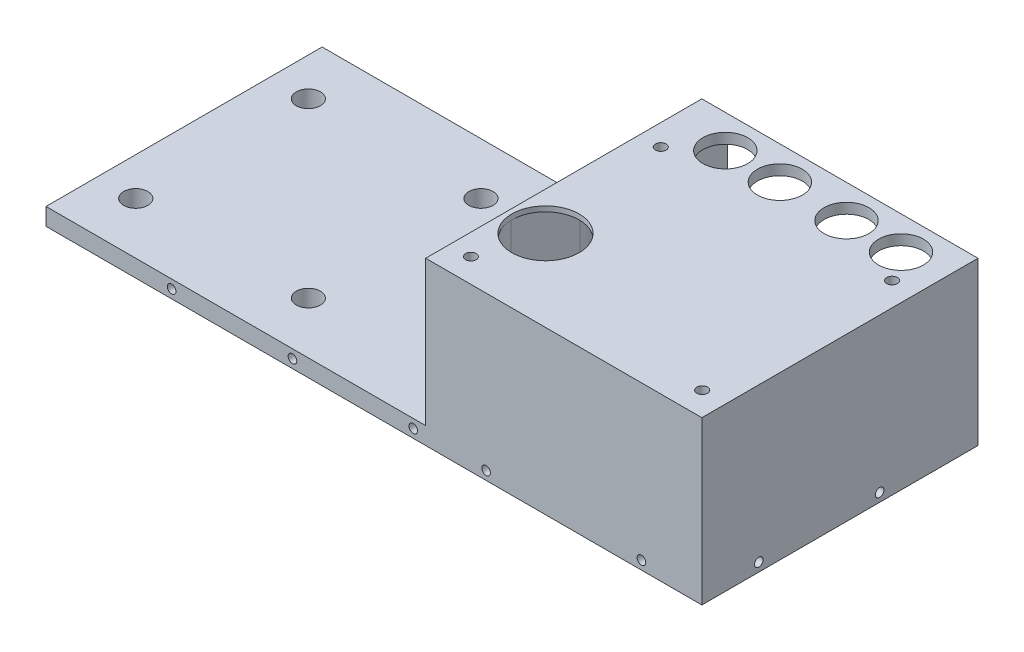
from build123d import *

# Parameters (mm, degrees)
SKETCH1_W                  = 190
SKETCH1_H                  = 80
BOSS_EXTRUDE1_DEPTH        = 5
SKETCH3_W                  = 80
SKETCH3_H                  = 80
BOSS_EXTRUDE2_DEPTH        = 42
SKETCH5_R                  = 6.5
CUT_EXTRUDE2_DEPTH         = 48
CUT_EXTRUDE3_DEPTH         = 44
SKETCH7_R                  = 3.5
CUT_EXTRUDE4_DEPTH         = 48
SKETCH8_R                  = 9.75
CUT_EXTRUDE5_DEPTH         = 48
SKETCH4_R                  = 1.55
CUT_EXTRUDE1_DEPTH         = 48
SKETCH9_R                  = 3.5
CUT_EXTRUDE6_DEPTH         = 44
SKETCH10_R                 = 10
CUT_EXTRUDE7_DEPTH         = 45.5
M3_TAPPED_HOLE1_AT_2_COUNT = 2
M3_TAPPED_HOLE1_AT_2_PITCH = 35
M3_TAPPED_HOLE1_AT_3_COUNT = 2
M3_TAPPED_HOLE1_AT_3_PITCH = 70
M3_TAPPED_HOLE2_D          = 2.5
M3_TAPPED_HOLE2_DEPTH      = 7.5
M3_TAPPED_HOLE2_TIP        = 0.751075774
M3_TAPPED_HOLE3_D          = 2.5
M3_TAPPED_HOLE3_DEPTH      = 7.5
M3_TAPPED_HOLE3_TIP        = 0.751075774
CUT_EXTRUDE8_DEPTH         = 45.5
FILLET1_R                  = 5
SKETCH_1_W                 = 68.9
SKETCH_1_H                 = 9.6
CUT_EXTRUDE_1_DEPTH        = 44


with BuildPart() as part:
    # Sketch1 → Boss-Extrude1 (new body)
    with BuildSketch(Plane(origin=(0, 0, 0), x_dir=(1, 0, 0), z_dir=(0, 1, 0))):
        Rectangle(SKETCH1_W, SKETCH1_H)
    extrude(amount=BOSS_EXTRUDE1_DEPTH)

    # Sketch3 → Boss-Extrude2 (add)
    with BuildSketch(Plane(origin=(0, 5, 0), x_dir=(1, 0, 0), z_dir=(0, 1, 0))):
        with Locations((55, 0)):
            Rectangle(SKETCH3_W, SKETCH3_H)
    extrude(amount=BOSS_EXTRUDE2_DEPTH)

    # Sketch5 → Cut-Extrude2 (cut, through all)
    with BuildSketch(Plane.XZ):
        with Locations((31.4, -30.4)):
            Circle(SKETCH5_R)
        with Locations((47.2, -30.4)):
            Circle(SKETCH5_R)
        with Locations((66.5, -30.4)):
            Circle(SKETCH5_R)
        with Locations((82.3, -30.4)):
            Circle(SKETCH5_R)
    extrude(amount=-CUT_EXTRUDE2_DEPTH, mode=Mode.SUBTRACT)

    # Sketch6 → Cut-Extrude3 (cut)
    with BuildSketch(Plane.XZ):
        with BuildLine():
            Line((31.4, -21.4), (82.3, -21.4))
            ThreePointArc((82.3, -21.4), (91.3, -30.4), (82.3, -39.4))
            Line((82.3, -39.4), (31.4, -39.4))
            ThreePointArc((31.4, -39.4), (22.4, -30.4), (31.4, -21.4))
        make_face()
    extrude(amount=-CUT_EXTRUDE3_DEPTH, mode=Mode.SUBTRACT)

    # Sketch7 → Cut-Extrude4 (cut, through all)
    with BuildSketch(Plane.XZ):
        with Locations((-84, 25)):
            Circle(SKETCH7_R)
        with Locations((-34, 25)):
            Circle(SKETCH7_R)
        with Locations((-84, -25)):
            Circle(SKETCH7_R)
        with Locations((-34, -25)):
            Circle(SKETCH7_R)
    extrude(amount=-CUT_EXTRUDE4_DEPTH, mode=Mode.SUBTRACT)

    # Sketch8 → Cut-Extrude5 (cut, through all)
    with BuildSketch(Plane.XZ):
        with Locations((26.1, 16.4)):
            Circle(SKETCH8_R)
    extrude(amount=-CUT_EXTRUDE5_DEPTH, mode=Mode.SUBTRACT)

    # Sketch4 → Cut-Extrude1 (cut, through all)
    with BuildSketch(Plane(origin=(0, 47, 0), x_dir=(1, 0, 0), z_dir=(0, 1, 0))):
        with Locations((21.15, 21.95)):
            Circle(SKETCH4_R)
        with Locations((88.15, 21.95)):
            Circle(SKETCH4_R)
        with Locations((21.15, -33.05)):
            Circle(SKETCH4_R)
        with Locations((88.15, -33.05)):
            Circle(SKETCH4_R)
    extrude(amount=-CUT_EXTRUDE1_DEPTH, mode=Mode.SUBTRACT)

    # Sketch9 → Cut-Extrude6 (cut)
    with BuildSketch(Plane.XZ):
        with Locations((21.15, -21.95)):
            Circle(SKETCH9_R)
        with Locations((88.15, -21.95)):
            Circle(SKETCH9_R)
        with Locations((21.15, 33.05)):
            Circle(SKETCH9_R)
        with Locations((88.15, 33.05)):
            Circle(SKETCH9_R)
    extrude(amount=-CUT_EXTRUDE6_DEPTH, mode=Mode.SUBTRACT)

    # Sketch10 → Cut-Extrude7 (cut)
    with BuildSketch(Plane.XZ):
        with Locations((26.1, 16.4)):
            Circle(SKETCH10_R)
    extrude(amount=-CUT_EXTRUDE7_DEPTH, mode=Mode.SUBTRACT)

    # Sketch15 → M3 Tapped Hole1 (revolve, cut)
    with BuildSketch(Plane(origin=(11.4, 2.5, -40), x_dir=(0, 1, 0), z_dir=(1, 0, 0))):
        Polygon((0, 0), (0, 9.251075774), (1.25, 8.5), (1.25, 0), align=None)
    m3_tapped_hole1 = revolve(axis=Axis((11.4, 2.5, -46.35), (0, 0, 1)), mode=Mode.SUBTRACT)

    # M3 Tapped Hole1 at 2: M3 Tapped Hole1 ×2
    with Locations(*[(-i * M3_TAPPED_HOLE1_AT_2_PITCH, 0, 0) for i in range(1, M3_TAPPED_HOLE1_AT_2_COUNT)]):
        add(m3_tapped_hole1, mode=Mode.SUBTRACT)

    # M3 Tapped Hole1 at 3: M3 Tapped Hole1 ×2
    with Locations(*[(-i * M3_TAPPED_HOLE1_AT_3_PITCH, 0, 0) for i in range(1, M3_TAPPED_HOLE1_AT_3_COUNT)]):
        add(m3_tapped_hole1, mode=Mode.SUBTRACT)

    # Mirror1: M3 Tapped Hole1 across plane
    add(m3_tapped_hole1.mirror(Plane.XY), mode=Mode.SUBTRACT)

    # Mirror1 copy 1 sketch → Mirror1 copy 1 (revolve, cut)
    with BuildSketch(Plane(origin=(-23.6, 2.5, 40), x_dir=(0, 1, 0), z_dir=(1, 0, 0))):
        Polygon((0, 0), (0, -9.251075774), (1.25, -8.5), (1.25, 0), align=None)
    revolve(axis=Axis((-23.6, 2.5, 46.35), (0, 0, 1)), mode=Mode.SUBTRACT)

    # Mirror1 copy 2 sketch → Mirror1 copy 2 (revolve, cut)
    with BuildSketch(Plane(origin=(-58.6, 2.5, 40), x_dir=(0, 1, 0), z_dir=(1, 0, 0))):
        Polygon((0, 0), (0, -9.251075774), (1.25, -8.5), (1.25, 0), align=None)
    revolve(axis=Axis((-58.6, 2.5, 46.35), (0, 0, 1)), mode=Mode.SUBTRACT)

    # M3 Tapped Hole2
    with Locations(Plane(origin=(32.5, 2.5, 40), x_dir=(1, 0, 0), z_dir=(0, 0, 1))):
        with Locations((0, 0), (45, 0)):
            Hole(M3_TAPPED_HOLE2_D / 2, depth=M3_TAPPED_HOLE2_DEPTH)
            with Locations((0, 0, -(M3_TAPPED_HOLE2_DEPTH + M3_TAPPED_HOLE2_TIP / 2))):  # 118° drill point
                Cone(0, M3_TAPPED_HOLE2_D / 2, M3_TAPPED_HOLE2_TIP, mode=Mode.SUBTRACT)

    # M3 Tapped Hole3
    with Locations(Plane(origin=(95, 2.5, 23.5), x_dir=(0, 0, 1), z_dir=(1, 0, 0))):
        with Locations((0, 0), (-35, 0)):
            Hole(M3_TAPPED_HOLE3_D / 2, depth=M3_TAPPED_HOLE3_DEPTH)
            with Locations((0, 0, -(M3_TAPPED_HOLE3_DEPTH + M3_TAPPED_HOLE3_TIP / 2))):  # 118° drill point
                Cone(0, M3_TAPPED_HOLE3_D / 2, M3_TAPPED_HOLE3_TIP, mode=Mode.SUBTRACT)

    # Sketch21 → Cut-Extrude8 (cut)
    with BuildSketch(Plane.XZ):
        Polygon((16.1, 16.4), (26.1, 16.4), (26.1, 26.4), (51.1, 26.4), (51.1, -8.6), (16.1, -8.6), align=None)
    extrude(amount=-CUT_EXTRUDE8_DEPTH, mode=Mode.SUBTRACT)

    # Fillet1
    fillet1_edges = [part.edges().sort_by_distance(p)[0] for p in [
        (16.1, 22.75, -8.6),
        (51.1, 22.75, 26.4),
        (51.1, 22.75, -8.6),
    ]]
    fillet(fillet1_edges, radius=FILLET1_R)

    # 草图1 → 切除-拉伸1 (cut)
    with BuildSketch(Plane.XZ):
        with Locations((56.85, -35.2)):
            Rectangle(SKETCH_1_W, SKETCH_1_H)
    extrude(amount=-CUT_EXTRUDE_1_DEPTH, mode=Mode.SUBTRACT)


solid = part.part
